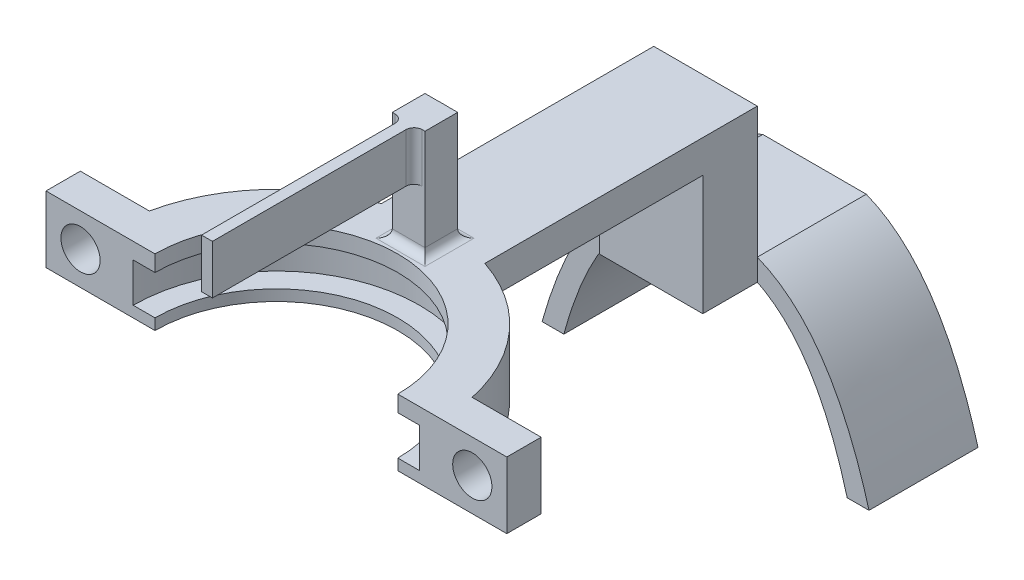
from build123d import *

# Parameters (mm, degrees)
BOSS_EXTRUDE1_DEPTH = 8.5
BOSS_EXTRUDE2_DEPTH = 3
BOSS_EXTRUDE3_DEPTH = 3
SKETCH10_W          = 9.5
SKETCH10_H          = 5
BOSS_EXTRUDE4_DEPTH = 11
SKETCH11_W          = 9.5
SKETCH11_H          = 2
BOSS_EXTRUDE5_DEPTH = 10
BOSS_EXTRUDE6_DEPTH = 6.09393
SKETCH14_R          = 1.8
CUT_EXTRUDE1_DEPTH  = 6.3
SKETCH15_W          = 51.153217575
SKETCH15_H          = 21.210560201
CUT_EXTRUDE3_DEPTH  = 15
SKETCH18_W          = 3
SKETCH18_H          = 3
BOSS_EXTRUDE7_DEPTH = 8.5
FILLET1_R           = 0.75
BOSS_EXTRUDE8_DEPTH = 1.5
FILLET2_R           = 0.75
BOSS_EXTRUDE9_DEPTH = 10


with BuildPart() as part:
    # Sketch3 → Revolve1 (revolve)
    with BuildSketch(Plane.XY):
        Polygon((-62.694264441, 11.733728816), (-64.884531744, 11.733728816), (-64.884531744, 5.639799249), (-60.884531744, 5.639799249), (-60.884531744, 6.650679103), (-62.884531744, 6.650679103), (-62.884531744, 10.250679103), (-60.884531744, 10.250679103), (-60.884531744, 11.733728816), align=None)
    revolve(axis=Axis((-49.744264441, 0, 0), (0, 1, 0)))

    # Sketch7 → Boss-Extrude1 (add)
    with BuildSketch(Plane(origin=(0, 11.733728816, 0), x_dir=(1, 0, 0), z_dir=(0, 1, 0))):
        with BuildLine():
            Line((-50.244264441, 15.132008921), (-50.244264441, 13.130751112))
            ThreePointArc((-50.244264441, 13.130751112), (-49.744264441, 13.140267302), (-49.244264441, 13.130751112))
            Line((-49.244264441, 13.130751112), (-49.244264441, 15.132008921))
            ThreePointArc((-49.244264441, 15.132008921), (-49.744264441, 15.140267302), (-50.244264441, 15.132008921))
        make_face()
    extrude(amount=BOSS_EXTRUDE1_DEPTH)

    # Sketch8 → Boss-Extrude2 (add)
    with BuildSketch(Plane(origin=(0, 20.233728816, 0), x_dir=(1, 0, 0), z_dir=(0, 1, 0))):
        with BuildLine():
            Line((-50.244264441, 15.132008921), (-50.244264441, 13.130751112))
            Line((-50.244264441, 13.130751112), (-50.244264441, -6.369248888))
            Line((-50.244264441, -6.369248888), (-49.244264441, -6.369248888))
            Line((-49.244264441, -6.369248888), (-49.244264441, 13.130751112))
            Line((-49.244264441, 13.130751112), (-49.244264441, 15.132008921))
            ThreePointArc((-49.244264441, 15.132008921), (-49.744264441, 15.140267302), (-50.244264441, 15.132008921))
        make_face()
    extrude(amount=-BOSS_EXTRUDE2_DEPTH)

    # Sketch9 → Boss-Extrude3 (add)
    with BuildSketch(Plane(origin=(0, 11.733728816, 0), x_dir=(1, 0, 0), z_dir=(0, 1, 0))):
        with BuildLine():
            Line((-54.494264441, 14.375854548), (-54.494264441, 39.375854548))
            Line((-54.494264441, 39.375854548), (-44.994264441, 39.375854548))
            Line((-44.994264441, 39.375854548), (-44.994264441, 14.375854548))
            ThreePointArc((-44.994264441, 14.375854548), (-47.092177082, 14.906177465), (-49.244264441, 15.132008921))
            ThreePointArc((-49.244264441, 15.132008921), (-49.744264441, 15.140267302), (-50.244264441, 15.132008921))
            ThreePointArc((-50.244264441, 15.132008921), (-52.3963518, 14.906177465), (-54.494264441, 14.375854548))
        make_face()
    extrude(amount=-BOSS_EXTRUDE3_DEPTH)

    # Sketch10 → Boss-Extrude4 (add)
    with BuildSketch(Plane.XZ.offset(-8.733728816)):
        with Locations((-49.744264441, -36.875854548)):
            Rectangle(SKETCH10_W, SKETCH10_H)
    extrude(amount=BOSS_EXTRUDE4_DEPTH)

    # Sketch11 → Boss-Extrude5 (add)
    with BuildSketch(Plane(origin=(0, 0, -39.375854548), x_dir=(-1, 0, 0), z_dir=(0, 0, -1))):
        with Locations((49.744264441, -1.266271184)):
            Rectangle(SKETCH11_W, SKETCH11_H)
    extrude(amount=BOSS_EXTRUDE5_DEPTH)

    # Sketch13 → Boss-Extrude6 (add)
    with BuildSketch(Plane(origin=(0, 11.733728816, 0), x_dir=(1, 0, 0), z_dir=(0, 1, 0))):
        with BuildLine():
            Line((-28.603997139, 3.15), (-34.935307895, 3.15))
            ThreePointArc((-34.935307895, 3.15), (-34.603997139, 0), (-34.935307895, -3.15))
            Line((-34.935307895, -3.15), (-28.603997139, -3.15))
            Line((-28.603997139, -3.15), (-28.603997139, 3.15))
        make_face()
        with BuildLine():
            Line((-70.884531744, 3.15), (-70.884531744, -3.15))
            Line((-70.884531744, -3.15), (-64.553220987, -3.15))
            ThreePointArc((-64.553220987, -3.15), (-64.884531744, 0), (-64.553220987, 3.15))
            Line((-64.553220987, 3.15), (-70.884531744, 3.15))
        make_face()
    extrude(amount=-BOSS_EXTRUDE6_DEPTH)

    # Sketch14 → Cut-Extrude1 (cut)
    with BuildSketch(Plane.XY.offset(3.15)):
        with Locations((-31.769652517, 8.686764033)):
            Circle(SKETCH14_R)
        with Locations((-67.718876365, 8.686764033)):
            Circle(SKETCH14_R)
    extrude(amount=-CUT_EXTRUDE1_DEPTH, mode=Mode.SUBTRACT)

    # Sketch15 → Cut-Extrude3 (cut, through all)
    with BuildSketch(Plane(origin=(0, 11.733728816, 0), x_dir=(1, 0, 0), z_dir=(0, 1, 0))):
        with Locations((-49.018725857, -10.6052801)):
            Rectangle(SKETCH15_W, SKETCH15_H)
    extrude(amount=-CUT_EXTRUDE3_DEPTH, mode=Mode.SUBTRACT)

    # Sketch18 → Boss-Extrude7 (add)
    with BuildSketch(Plane(origin=(0, 11.733728816, 0), x_dir=(1, 0, 0), z_dir=(0, 1, 0))):
        with Locations((-49.744264441, 13.632008921)):
            Rectangle(SKETCH18_W, SKETCH18_H)
    extrude(amount=BOSS_EXTRUDE7_DEPTH)

    # Fillet1
    fillet1_edges = [part.edges().sort_by_distance(p)[0] for p in [
        (-50.744264441, 11.733728816, -15.132008921),
        (-48.744264441, 11.733728816, -15.132008921),
        (-49.744264441, 11.733728816, -12.132008921),
        (-48.244264441, 11.733728816, -13.632008921),
        (-51.244264441, 11.733728816, -13.632008921),
        (-49.744264441, 11.733728816, -15.140267302),
    ]]
    fillet(fillet1_edges, radius=FILLET1_R)

    # Sketch19 → Boss-Extrude8 (add)
    with BuildSketch(Plane(origin=(0, 20.233728816, 0), x_dir=(1, 0, 0), z_dir=(0, 1, 0))):
        with BuildLine():
            Line((-50.244264441, 15.132008921), (-51.244264441, 15.132008921))
            Line((-51.244264441, 15.132008921), (-51.244264441, 12.132008921))
            Line((-51.244264441, 12.132008921), (-50.244264441, 12.132008921))
            Line((-50.244264441, 12.132008921), (-50.244264441, -6.369248888))
            Line((-50.244264441, -6.369248888), (-49.244264441, -6.369248888))
            Line((-49.244264441, -6.369248888), (-49.244264441, 12.132008921))
            Line((-49.244264441, 12.132008921), (-48.244264441, 12.132008921))
            Line((-48.244264441, 12.132008921), (-48.244264441, 15.132008921))
            Line((-48.244264441, 15.132008921), (-49.244264441, 15.132008921))
            ThreePointArc((-49.244264441, 15.132008921), (-49.744264441, 15.140267302), (-50.244264441, 15.132008921))
        make_face()
    extrude(amount=BOSS_EXTRUDE8_DEPTH)

    # Fillet2
    fillet2_edges = [part.edges().sort_by_distance(p)[0] for p in [
        (-50.244264441, 19.483728816, -12.132008921),
        (-49.244264441, 19.483728816, -12.132008921),
    ]]
    fillet(fillet2_edges, radius=FILLET2_R)

    # Sketch20 → Boss-Extrude9 (add)
    with BuildSketch(Plane(origin=(0, 0, -49.375854548), x_dir=(-1, 0, 0), z_dir=(0, 0, -1))):
        with BuildLine():
            Line((34.744264441, -15.266271184), (36.744264441, -15.266271184))
            add(Edge.make_bspline(
                [(36.744264441, -15.266271184), (39.582311707, -4.870122804), (44.994264441, -2.266271184)],
                knots=[0, 0, 0, 0.599407443, 0.599407443, 0.599407443], degree=2))
            Line((44.994264441, -2.266271184), (54.494264441, -2.266271184))
            add(Edge.make_bspline(
                [(54.494264441, -2.266271184), (59.906217176, -4.870122804), (62.744264441, -15.266271184)],
                knots=[0.400592557, 0.400592557, 0.400592557, 1, 1, 1], degree=2))
            Line((62.744264441, -15.266271184), (64.744264441, -15.266271184))
            add(Edge.make_bspline(
                [(64.744264441, -15.266271184), (61.29176104, -2.966792571), (54.494264441, -0.266271184)],
                knots=[0, 0, 0, 0.639930482, 0.639930482, 0.639930482], degree=2))
            Line((54.494264441, -0.266271184), (44.994264441, -0.266271184))
            add(Edge.make_bspline(
                [(34.744264441, -15.266271184), (38.196767843, -2.966792571), (44.994264441, -0.266271184)],
                knots=[0, 0, 0, 0.639930482, 0.639930482, 0.639930482], degree=2))
        make_face()
    extrude(amount=-BOSS_EXTRUDE9_DEPTH)


solid = part.part
